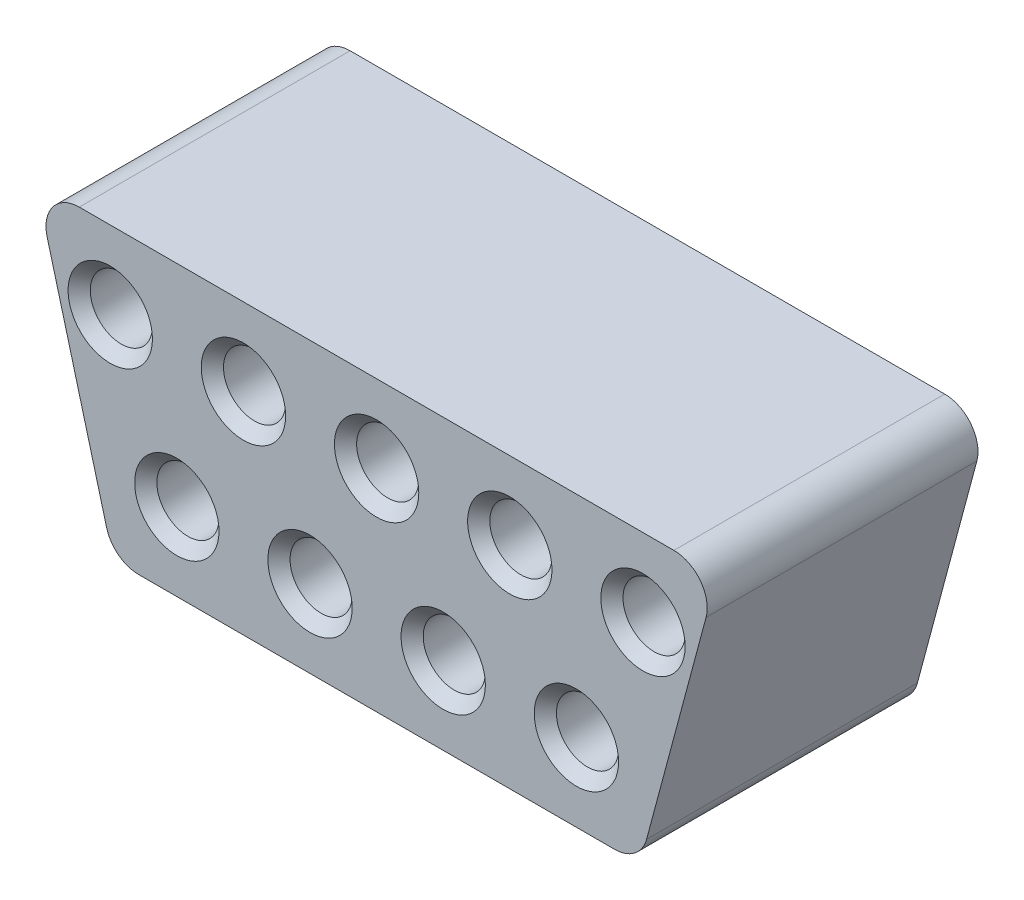
from build123d import *

# Parameters (mm, degrees)
BOSS_EXTRUDE1_DEPTH = 6.1
CUT_EXTRUDE1_REACH  = 12.16
SKETCH2_R           = 0.7
CHAMFER1_SIZE       = 0.25


with BuildPart() as part:
    # Sketch1 → Boss-Extrude1 (new body)
    with BuildSketch(Plane.XY):
        with BuildLine():
            ThreePointArc((-6.081784137, -2.694114284), (-5.813910839, -3.095015005), (-5.357339767, -3.25))
            Line((-5.357339767, -3.25), (5.357339767, -3.25))
            ThreePointArc((5.357339767, -3.25), (5.813910839, -3.095015005), (6.081784137, -2.694114284))
            Line((6.081784137, -2.694114284), (7.421530099, 2.305885716))
            ThreePointArc((7.421530099, 2.305885716), (7.292100735, 2.956571072), (6.697085729, 3.25))
            Line((6.697085729, 3.25), (-6.697085729, 3.25))
            ThreePointArc((-6.697085729, 3.25), (-7.292100735, 2.956571072), (-7.421530099, 2.305885716))
            Line((-7.421530099, 2.305885716), (-6.081784137, -2.694114284))
        make_face()
    extrude(amount=BOSS_EXTRUDE1_DEPTH)

    # Sketch2 → Cut-Extrude1 (cut, up to next)
    with BuildSketch(Plane.XY.offset(6.1), mode=Mode.PRIVATE) as cut_extrude1_sk1:
        with Locations((-5.999496922, 1.5)):
            Circle(SKETCH2_R)
    cut_extrude1_tool1 = extrude(cut_extrude1_sk1.sketch, amount=-CUT_EXTRUDE1_REACH, mode=Mode.PRIVATE) & part.part
    # Sketch2 → Cut-Extrude1 (cut, up to next)
    with BuildSketch(Plane.XY.offset(6.1), mode=Mode.PRIVATE) as cut_extrude1_sk2:
        with Locations((-2.999496922, 1.5)):
            Circle(SKETCH2_R)
    cut_extrude1_tool2 = extrude(cut_extrude1_sk2.sketch, amount=-CUT_EXTRUDE1_REACH, mode=Mode.PRIVATE) & part.part
    # Sketch2 → Cut-Extrude1 (cut, up to next)
    with BuildSketch(Plane.XY.offset(6.1), mode=Mode.PRIVATE) as cut_extrude1_sk3:
        with Locations((0.000503078, 1.5)):
            Circle(SKETCH2_R)
    cut_extrude1_tool3 = extrude(cut_extrude1_sk3.sketch, amount=-CUT_EXTRUDE1_REACH, mode=Mode.PRIVATE) & part.part
    # Sketch2 → Cut-Extrude1 (cut, up to next)
    with BuildSketch(Plane.XY.offset(6.1), mode=Mode.PRIVATE) as cut_extrude1_sk4:
        with Locations((3.000503078, 1.5)):
            Circle(SKETCH2_R)
    cut_extrude1_tool4 = extrude(cut_extrude1_sk4.sketch, amount=-CUT_EXTRUDE1_REACH, mode=Mode.PRIVATE) & part.part
    # Sketch2 → Cut-Extrude1 (cut, up to next)
    with BuildSketch(Plane.XY.offset(6.1), mode=Mode.PRIVATE) as cut_extrude1_sk5:
        with Locations((6.000503078, 1.5)):
            Circle(SKETCH2_R)
    cut_extrude1_tool5 = extrude(cut_extrude1_sk5.sketch, amount=-CUT_EXTRUDE1_REACH, mode=Mode.PRIVATE) & part.part
    # Sketch2 → Cut-Extrude1 (cut, up to next)
    with BuildSketch(Plane.XY.offset(6.1), mode=Mode.PRIVATE) as cut_extrude1_sk6:
        with Locations((-4.499496922, -1.5)):
            Circle(SKETCH2_R)
    cut_extrude1_tool6 = extrude(cut_extrude1_sk6.sketch, amount=-CUT_EXTRUDE1_REACH, mode=Mode.PRIVATE) & part.part
    # Sketch2 → Cut-Extrude1 (cut, up to next)
    with BuildSketch(Plane.XY.offset(6.1), mode=Mode.PRIVATE) as cut_extrude1_sk7:
        with Locations((-1.499496922, -1.5)):
            Circle(SKETCH2_R)
    cut_extrude1_tool7 = extrude(cut_extrude1_sk7.sketch, amount=-CUT_EXTRUDE1_REACH, mode=Mode.PRIVATE) & part.part
    # Sketch2 → Cut-Extrude1 (cut, up to next)
    with BuildSketch(Plane.XY.offset(6.1), mode=Mode.PRIVATE) as cut_extrude1_sk8:
        with Locations((1.500503078, -1.5)):
            Circle(SKETCH2_R)
    cut_extrude1_tool8 = extrude(cut_extrude1_sk8.sketch, amount=-CUT_EXTRUDE1_REACH, mode=Mode.PRIVATE) & part.part
    # Sketch2 → Cut-Extrude1 (cut, up to next)
    with BuildSketch(Plane.XY.offset(6.1), mode=Mode.PRIVATE) as cut_extrude1_sk9:
        with Locations((4.500503078, -1.5)):
            Circle(SKETCH2_R)
    cut_extrude1_tool9 = extrude(cut_extrude1_sk9.sketch, amount=-CUT_EXTRUDE1_REACH, mode=Mode.PRIVATE) & part.part
    add(cut_extrude1_tool1.solids().sort_by_distance((-5.999497, 1.5, 6.1))[0], mode=Mode.SUBTRACT)
    add(cut_extrude1_tool2.solids().sort_by_distance((-2.999497, 1.5, 6.1))[0], mode=Mode.SUBTRACT)
    add(cut_extrude1_tool3.solids().sort_by_distance((0.000503, 1.5, 6.1))[0], mode=Mode.SUBTRACT)
    add(cut_extrude1_tool4.solids().sort_by_distance((3.000503, 1.5, 6.1))[0], mode=Mode.SUBTRACT)
    add(cut_extrude1_tool5.solids().sort_by_distance((6.000503, 1.5, 6.1))[0], mode=Mode.SUBTRACT)
    add(cut_extrude1_tool6.solids().sort_by_distance((-4.499497, -1.5, 6.1))[0], mode=Mode.SUBTRACT)
    add(cut_extrude1_tool7.solids().sort_by_distance((-1.499497, -1.5, 6.1))[0], mode=Mode.SUBTRACT)
    add(cut_extrude1_tool8.solids().sort_by_distance((1.500503, -1.5, 6.1))[0], mode=Mode.SUBTRACT)
    add(cut_extrude1_tool9.solids().sort_by_distance((4.500503, -1.5, 6.1))[0], mode=Mode.SUBTRACT)

    # Chamfer1
    chamfer1_edges = [part.edges().sort_by_distance(p)[0] for p in [
        (-5.199496922, -1.5, 6.1),
        (-2.199496922, -1.5, 6.1),
        (0.800503078, -1.5, 6.1),
        (3.800503078, -1.5, 6.1),
        (5.300503078, 1.5, 6.1),
        (2.300503078, 1.5, 6.1),
        (-0.699496922, 1.5, 6.1),
        (-3.699496922, 1.5, 6.1),
        (-6.699496922, 1.5, 6.1),
    ]]
    chamfer(chamfer1_edges, length=CHAMFER1_SIZE)


solid = part.part
